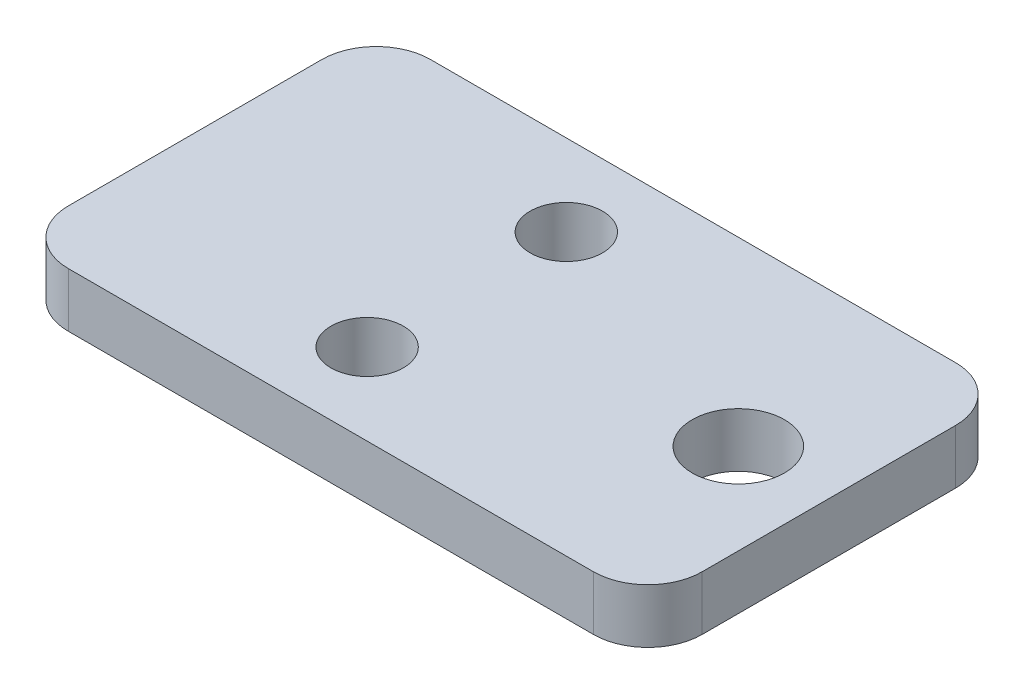
from build123d import *

# Parameters (mm, degrees)
SKETCH1_R           = 2.55
SKETCH1_R_2         = 2
BOSS_EXTRUDE1_DEPTH = 3


with BuildPart() as part:
    # Sketch1 → Boss-Extrude1 (new body)
    with BuildSketch(Plane(origin=(0, 0, 0), x_dir=(1, 0, 0), z_dir=(0, 1, 0))):
        with BuildLine():
            Line((-14.5, 10), (14.5, 10))
            ThreePointArc((14.5, 10), (16.621320344, 9.121320344), (17.5, 7))
            Line((17.5, 7), (17.5, -7))
            ThreePointArc((17.5, -7), (16.621320344, -9.121320344), (14.5, -10))
            Line((14.5, -10), (-14.5, -10))
            ThreePointArc((-14.5, -10), (-16.621320344, -9.121320344), (-17.5, -7))
            Line((-17.5, -7), (-17.5, 7))
            ThreePointArc((-17.5, 7), (-16.621320344, 9.121320344), (-14.5, 10))
        make_face()
        with Locations((12.5, 0)):
            Circle(SKETCH1_R, mode=Mode.SUBTRACT)
        with Locations((-2.5, 5.5)):
            Circle(SKETCH1_R_2, mode=Mode.SUBTRACT)
        with Locations((-2.5, -5.5)):
            Circle(SKETCH1_R_2, mode=Mode.SUBTRACT)
    extrude(amount=BOSS_EXTRUDE1_DEPTH)


solid = part.part
